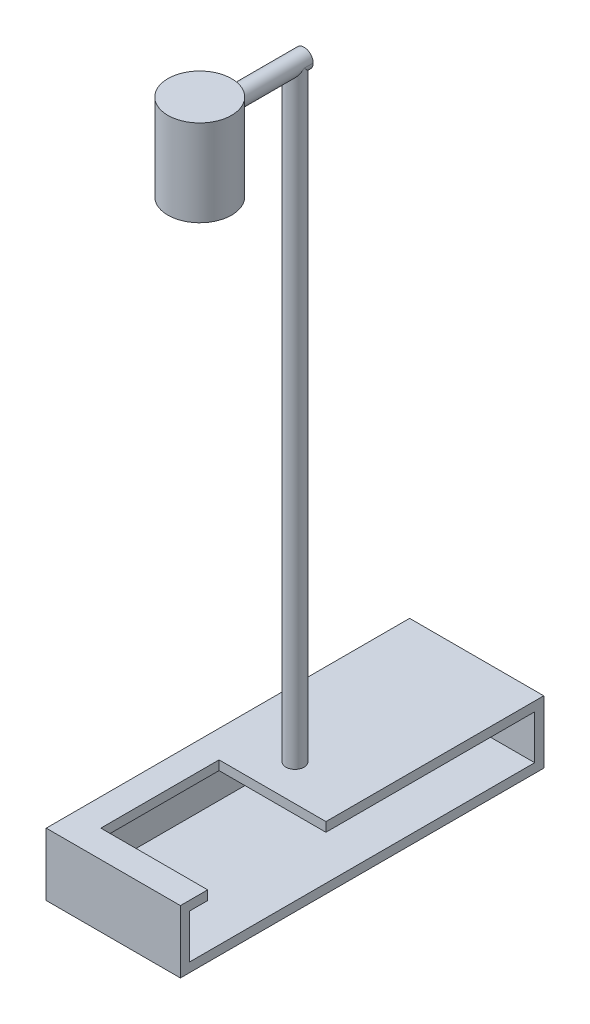
from build123d import *
from build123d.topology import SkipClean

# Parameters (mm, degrees)
SKETCH4_R           = 2
BOSS_EXTRUDE1_DEPTH = 140
SKETCH5_W           = 29.5
SKETCH5_H           = 13.79
BOSS_EXTRUDE3_DEPTH = 79.9
SKETCH6_W           = 75.9
SKETCH6_H           = 9.7
CUT_EXTRUDE1_DEPTH  = 27.5
SKETCH7_W           = 23.5
SKETCH7_H           = 26
CUT_EXTRUDE2_DEPTH  = 3
SKETCH8_R           = 2
BOSS_EXTRUDE4_DEPTH = 22.95
SKETCH12_R          = 7
BOSS_EXTRUDE6_DEPTH = 15.01
SKETCH13_R          = 7
BOSS_EXTRUDE7_DEPTH = 4
SKETCH14_R          = 5.5
CUT_EXTRUDE3_DEPTH  = 12


with BuildPart() as part:
    # Sketch4 → Boss-Extrude1 (new body)
    with BuildSketch(Plane(origin=(0, 0, 0), x_dir=(1, 0, 0), z_dir=(0, 1, 0))):
        with Locations(Location((0, -39.95, 0), (0, 0, 270))):
            Circle(SKETCH4_R)
    extrude(amount=BOSS_EXTRUDE1_DEPTH)

    # Sketch5 → Boss-Extrude3 (add)
    with BuildSketch(Plane.XY):
        Rectangle(SKETCH5_W, SKETCH5_H)
    extrude(amount=BOSS_EXTRUDE3_DEPTH)

    # Sketch6 → Cut-Extrude1 (cut)
    with BuildSketch(Plane(origin=(14.75, 0, 0), x_dir=(0, 0, -1), z_dir=(1, 0, 0))):
        with Locations((-39.95, 0)):
            Rectangle(SKETCH6_W, SKETCH6_H)
    extrude(amount=-CUT_EXTRUDE1_DEPTH, mode=Mode.SUBTRACT)

    # Sketch7 → Cut-Extrude2 (cut)
    with BuildSketch(Plane(origin=(0, 6.895, 0), x_dir=(1, 0, 0), z_dir=(0, 1, 0))):
        with Locations((3, -60.9)):
            Rectangle(SKETCH7_W, SKETCH7_H)
    extrude(amount=-CUT_EXTRUDE2_DEPTH, mode=Mode.SUBTRACT)

    # Sketch8 → Boss-Extrude4 (add)
    with SkipClean():  # the faces are left unmerged after this step: merging them gives an invalid solid
        with BuildSketch(Plane.XY.offset(37.95)):
            with Locations((0, 140)):
                Circle(SKETCH8_R)
        extrude(amount=BOSS_EXTRUDE4_DEPTH)

    # Sketch12 → Boss-Extrude6 (add)
    with SkipClean():  # the faces are left unmerged after this step: merging them gives an invalid solid
        with BuildSketch(Plane(origin=(0, 140, 0), x_dir=(1, 0, 0), z_dir=(0, 1, 0))):
            with Locations(Location((0, -60.9, 0), (0, 0, 270))):
                Circle(SKETCH12_R)
        extrude(amount=-BOSS_EXTRUDE6_DEPTH)

    # Sketch13 → Boss-Extrude7 (add)
    with SkipClean():  # the faces are left unmerged after this step: merging them gives an invalid solid
        with BuildSketch(Plane(origin=(0, 140, 0), x_dir=(1, 0, 0), z_dir=(0, 1, 0))):
            with Locations(Location((0, -60.9, 0), (0, 0, 270))):
                Circle(SKETCH13_R)
        extrude(amount=BOSS_EXTRUDE7_DEPTH)

    # Sketch14 → Cut-Extrude3 (cut)
    with SkipClean():  # the faces are left unmerged after this step: merging them gives an invalid solid
        with BuildSketch(Plane.XZ.offset(-124.99)):
            with Locations(Location((0, 60.9, 0), (0, 0, 270))):
                Circle(SKETCH14_R)
        extrude(amount=-CUT_EXTRUDE3_DEPTH, mode=Mode.SUBTRACT)


solid = part.part
